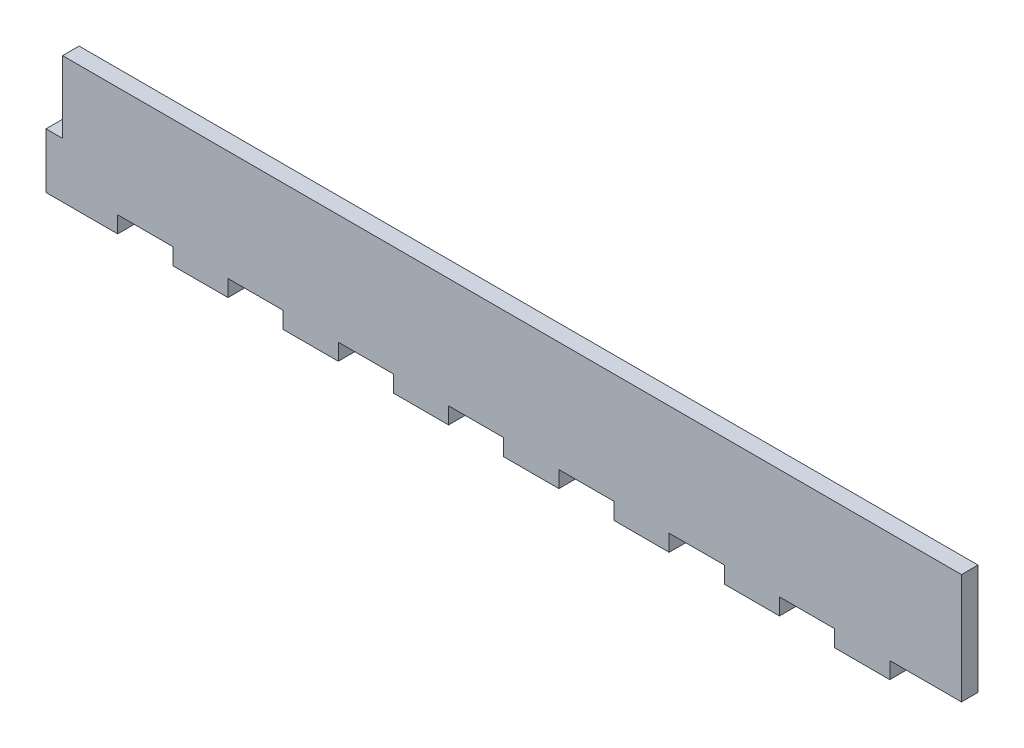
from build123d import *

# Parameters (mm, degrees)
ESQUISSE1_W                = 163
ESQUISSE1_H                = 20
BOSS_EXTRU_1_DEPTH         = 3
ESQUISSE2_W                = 10
ESQUISSE2_H                = 3
BOSS_EXTRU_2_DEPTH         = 3
R_P_TITION_LIN_AIRE1_COUNT = 8
R_P_TITION_LIN_AIRE1_PITCH = 20
ESQUISSE3_W                = 3
ESQUISSE3_H                = 10
BOSS_EXTRU_3_DEPTH         = 3


with BuildPart() as part:
    # Esquisse1 → Boss.-Extru.1 (new body)
    with BuildSketch(Plane.XY):
        with Locations((81.5, -10)):
            Rectangle(ESQUISSE1_W, ESQUISSE1_H)
    extrude(amount=BOSS_EXTRU_1_DEPTH)

    # Esquisse2 → Boss.-Extru.2 (add)
    with BuildSketch(Plane.XZ.offset(20)):
        with Locations((5, 1.5)):
            Rectangle(ESQUISSE2_W, ESQUISSE2_H)
    boss_extru_2 = extrude(amount=BOSS_EXTRU_2_DEPTH)

    # Répétition linéaire1: Boss.-Extru.2 ×8
    with Locations(*[(i * R_P_TITION_LIN_AIRE1_PITCH, 0, 0) for i in range(1, R_P_TITION_LIN_AIRE1_COUNT)]):
        add(boss_extru_2)

    # Esquisse3 → Boss.-Extru.3 (add)
    with BuildSketch(Plane.ZY):
        with Locations((1.5, -18)):
            Rectangle(ESQUISSE3_W, ESQUISSE3_H)
    extrude(amount=BOSS_EXTRU_3_DEPTH)


solid = part.part
